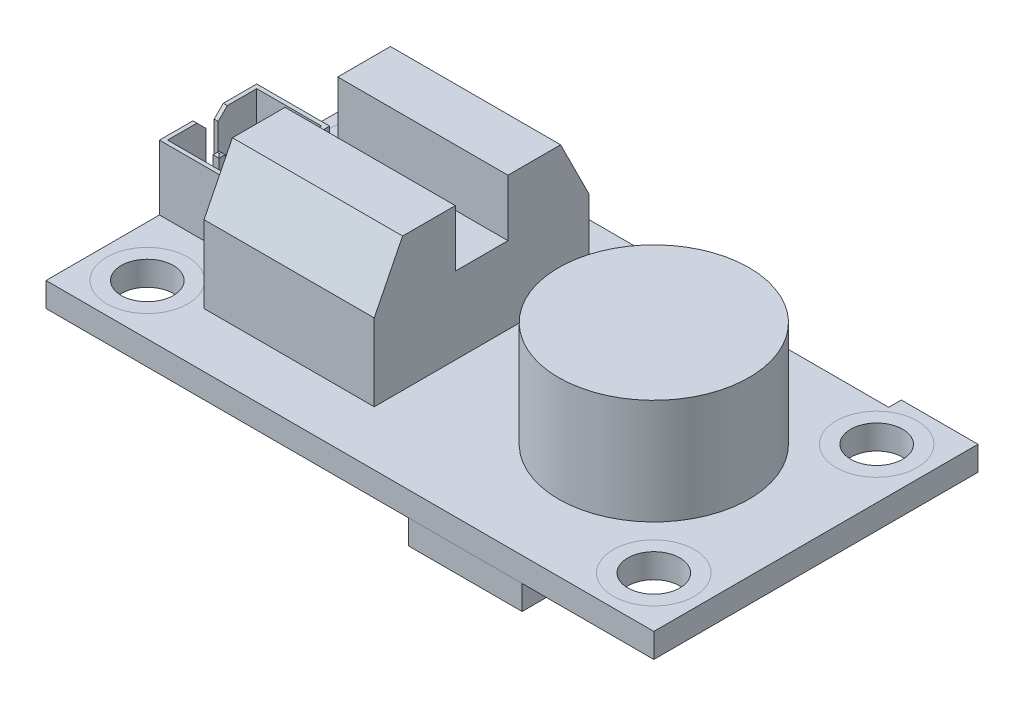
from build123d import *

# Parameters (mm, degrees)
SKETCH1_W               = 38.1
SKETCH1_H               = 20.32
BOSS_EXTRUDE1_DEPTH     = 1.524
F_4_CLEARANCE_HOLE1_D   = 3.2639
SKETCH4_W               = 4.572
SKETCH4_H               = 6.096
BOSS_EXTRUDE2_DEPTH     = 4.064
SKETCH5_R               = 5.969
BOSS_EXTRUDE3_DEPTH     = 6.604
SKETCH6_W               = 10.668
SKETCH6_H               = 13.462
BOSS_EXTRUDE4_DEPTH     = 4.826
BOSS_EXTRUDE5_DEPTH     = 10.668
SKETCH8_W               = 7.874
SKETCH8_H               = 5.588
BOSS_EXTRUDE6_DEPTH     = 3.048
SKETCH9_W               = 7.112
SKETCH9_H               = 5.08
BOSS_EXTRUDE7_DEPTH     = 1.524
SKETCH10_W              = 2.54
SKETCH10_H              = 4.064
BOSS_EXTRUDE8_DEPTH     = 1.016
SKETCH11_W              = 5.08
SKETCH11_H              = 5.08
BOSS_EXTRUDE9_DEPTH     = 1.016
SKETCH12_W              = 4.064
SKETCH12_H              = 2.032
BOSS_EXTRUDE10_DEPTH    = 1.016
SKETCH13_W              = 3.048
SKETCH13_H              = 3.048
BOSS_EXTRUDE11_DEPTH    = 0.508
SKETCH14_W              = 3.048
SKETCH14_H              = 3.556
BOSS_EXTRUDE12_DEPTH    = 1.016
SKETCH15_W              = 2.032
SKETCH15_H              = 4.064
BOSS_EXTRUDE13_DEPTH    = 1.524
SKETCH16_W              = 3.048
SKETCH16_H              = 3.048
BOSS_EXTRUDE14_DEPTH    = 1.016
SKETCH17_R              = 0.508
BOSS_EXTRUDE15_DEPTH    = 1.524
LPATTERN1_COUNT         = 4
LPATTERN1_PITCH         = 2.794
MIRROR1_COPY_1_SKETCH_R = 0.508
MIRROR1_COPY_1_DEPTH    = 1.524
MIRROR1_COPY_2_SKETCH_R = 0.508
MIRROR1_COPY_2_DEPTH    = 1.524
MIRROR1_COPY_3_SKETCH_R = 0.508
MIRROR1_COPY_3_DEPTH    = 1.524
SKETCH22_W              = 13.60805
SKETCH22_H              = 0.79375
CUT_EXTRUDE2_DEPTH      = 1.524
SKETCH24_W              = 4.064
SKETCH24_H              = 5.588
CUT_EXTRUDE3_DEPTH      = 3.556
SKETCH25_W              = 0.381
SKETCH25_H              = 0.381
BOSS_EXTRUDE16_DEPTH    = 3.048
CHAMFER1_SIZE           = 0.127
CUT_EXTRUDE4_DEPTH      = 0.254
CHAMFER2_SIZE           = 1.778
CHAMFER2_SIZE2          = 2.737879906
CHAMFER2_PART_2_SIZE    = 1.778
CHAMFER2_PART_2_SIZE2   = 2.737879906


with BuildPart() as part:
    # Sketch1 → Boss-Extrude1 (new body)
    with BuildSketch(Plane(origin=(0, 0, 0), x_dir=(1, 0, 0), z_dir=(0, 1, 0))):
        Rectangle(SKETCH1_W, SKETCH1_H)
    extrude(amount=BOSS_EXTRUDE1_DEPTH)

    # #4 Clearance Hole1 (through all)
    with Locations(Plane(origin=(0, 1.524, 0), x_dir=(1, 0, 0), z_dir=(0, 1, 0))):
        with Locations((-15.875, 6.985), (15.875, -6.985), (-15.875, -6.985), (15.875, 6.985)):
            Hole(F_4_CLEARANCE_HOLE1_D / 2)

    # Sketch4 → Boss-Extrude2 (add)
    with BuildSketch(Plane(origin=(0, 1.524, 0), x_dir=(1, 0, 0), z_dir=(0, 1, 0))):
        with Locations((-16.764, 0)):
            Rectangle(SKETCH4_W, SKETCH4_H)
    extrude(amount=BOSS_EXTRUDE2_DEPTH)

    # Sketch5 → Boss-Extrude3 (add)
    with BuildSketch(Plane(origin=(0, 1.524, 0), x_dir=(1, 0, 0), z_dir=(0, 1, 0))):
        with Locations((8.89, 0)):
            Circle(SKETCH5_R)
    extrude(amount=BOSS_EXTRUDE3_DEPTH)

    # Sketch6 → Boss-Extrude4 (add)
    with BuildSketch(Plane(origin=(0, 1.524, 0), x_dir=(1, 0, 0), z_dir=(0, 1, 0))):
        with Locations((-7.239, 0)):
            Rectangle(SKETCH6_W, SKETCH6_H)
    extrude(amount=BOSS_EXTRUDE4_DEPTH)

    # Sketch7 → Boss-Extrude5 (add)
    with BuildSketch(Plane.ZY.offset(12.573)):
        Polygon((-6.731, 6.35), (-4.953, 9.906), (-1.651, 9.906), (-1.651, 6.35), align=None)
        Polygon((6.731, 6.35), (4.953, 9.906), (1.651, 9.906), (1.651, 6.35), align=None)
    extrude(amount=-BOSS_EXTRUDE5_DEPTH)

    # Sketch8 → Boss-Extrude6 (add)
    with BuildSketch(Plane.XZ):
        with Locations((7.239, -7.366)):
            Rectangle(SKETCH8_W, SKETCH8_H)
    extrude(amount=BOSS_EXTRUDE6_DEPTH)

    # Sketch9 → Boss-Extrude7 (add)
    with BuildSketch(Plane.XZ):
        with Locations((7.239, 7.62)):
            Rectangle(SKETCH9_W, SKETCH9_H)
    extrude(amount=BOSS_EXTRUDE7_DEPTH)

    # Sketch10 → Boss-Extrude8 (add)
    with BuildSketch(Plane.XZ):
        with Locations((13.589, 0)):
            Rectangle(SKETCH10_W, SKETCH10_H)
    extrude(amount=BOSS_EXTRUDE8_DEPTH)

    # Sketch11 → Boss-Extrude9 (add)
    with BuildSketch(Plane.XZ):
        with Locations((4.191, 0)):
            Rectangle(SKETCH11_W, SKETCH11_H)
    extrude(amount=BOSS_EXTRUDE9_DEPTH)

    # Sketch12 → Boss-Extrude10 (add)
    with BuildSketch(Plane.XZ):
        with Locations((-2.413, 7.112)):
            Rectangle(SKETCH12_W, SKETCH12_H)
    extrude(amount=BOSS_EXTRUDE10_DEPTH)

    # Sketch13 → Boss-Extrude11 (add)
    with BuildSketch(Plane.XZ):
        with Locations((-3.81, -6.096)):
            Rectangle(SKETCH13_W, SKETCH13_H)
    extrude(amount=BOSS_EXTRUDE11_DEPTH)

    # Sketch14 → Boss-Extrude12 (add)
    with BuildSketch(Plane.XZ):
        with Locations((-9.906, -6.35)):
            Rectangle(SKETCH14_W, SKETCH14_H)
    extrude(amount=BOSS_EXTRUDE12_DEPTH)

    # Sketch15 → Boss-Extrude13 (add)
    with BuildSketch(Plane.XZ):
        with Locations((-15.494, 1.27)):
            Rectangle(SKETCH15_W, SKETCH15_H)
    extrude(amount=BOSS_EXTRUDE13_DEPTH)

    # Sketch16 → Boss-Extrude14 (add)
    with BuildSketch(Plane.XZ):
        with Locations((-9.398, 0)):
            Rectangle(SKETCH16_W, SKETCH16_H)
    extrude(amount=BOSS_EXTRUDE14_DEPTH)

    # Sketch17 → Boss-Extrude15 (add)
    with BuildSketch(Plane.XZ):
        with Locations((-11.684, -3.556)):
            Circle(SKETCH17_R)
    boss_extrude15 = extrude(amount=BOSS_EXTRUDE15_DEPTH)

    # LPattern1: Boss-Extrude15 ×4
    with Locations(*[(i * LPATTERN1_PITCH, 0, 0) for i in range(1, LPATTERN1_COUNT)]):
        add(boss_extrude15)

    # Mirror1: Boss-Extrude15 across plane
    add(boss_extrude15.mirror(Plane.XY))

    # Mirror1 copy 1 sketch → Mirror1 copy 1 (add)
    with BuildSketch(Plane(origin=(2.794, 0, 0), x_dir=(1, 0, 0), z_dir=(0, -1, 0))):
        with Locations((-11.684, 3.556)):
            Circle(MIRROR1_COPY_1_SKETCH_R)
    extrude(amount=MIRROR1_COPY_1_DEPTH)

    # Mirror1 copy 2 sketch → Mirror1 copy 2 (add)
    with BuildSketch(Plane(origin=(5.588, 0, 0), x_dir=(1, 0, 0), z_dir=(0, -1, 0))):
        with Locations((-11.684, 3.556)):
            Circle(MIRROR1_COPY_2_SKETCH_R)
    extrude(amount=MIRROR1_COPY_2_DEPTH)

    # Mirror1 copy 3 sketch → Mirror1 copy 3 (add)
    with BuildSketch(Plane(origin=(8.382, 0, 0), x_dir=(1, 0, 0), z_dir=(0, -1, 0))):
        with Locations((-11.684, 3.556)):
            Circle(MIRROR1_COPY_3_SKETCH_R)
    extrude(amount=MIRROR1_COPY_3_DEPTH)

    # Sketch22 → Cut-Extrude2 (cut)
    with BuildSketch(Plane(origin=(0, 1.524, 0), x_dir=(1, 0, 0), z_dir=(0, 1, 0))):
        with Locations((7.439025, 9.763125)):
            Rectangle(SKETCH22_W, SKETCH22_H)
    extrude(amount=-CUT_EXTRUDE2_DEPTH, mode=Mode.SUBTRACT)

    # Sketch24 → Cut-Extrude3 (cut)
    with BuildSketch(Plane(origin=(0, 5.588, 0), x_dir=(1, 0, 0), z_dir=(0, 1, 0))):
        with Locations((-16.764, 0)):
            Rectangle(SKETCH24_W, SKETCH24_H)
    extrude(amount=-CUT_EXTRUDE3_DEPTH, mode=Mode.SUBTRACT)

    # Sketch25 → Boss-Extrude16 (add)
    with BuildSketch(Plane(origin=(0, 2.032, 0), x_dir=(1, 0, 0), z_dir=(0, 1, 0))):
        with Locations((-17.018, 1.3335)):
            Rectangle(SKETCH25_W, SKETCH25_H)
        with Locations((-17.018, -1.3335)):
            Rectangle(SKETCH25_W, SKETCH25_H)
    extrude(amount=BOSS_EXTRUDE16_DEPTH)

    # Chamfer1
    chamfer1_edges = [part.edges().sort_by_distance(p)[0] for p in [
        (-17.018, 5.08, -1.524),
        (-17.2085, 5.08, -1.3335),
        (-17.018, 5.08, -1.143),
        (-16.8275, 5.08, -1.3335),
        (-17.018, 5.08, 1.143),
        (-17.2085, 5.08, 1.3335),
        (-17.018, 5.08, 1.524),
        (-16.8275, 5.08, 1.3335),
    ]]
    chamfer(chamfer1_edges, length=CHAMFER1_SIZE)

    # Sketch26 → Cut-Extrude4 (cut)
    with BuildSketch(Plane.ZY.offset(19.05)):
        Polygon((-0.9525, 5.588), (-0.381, 5.0165), (-0.381, 2.286), (0.381, 2.286), (0.381, 5.0165), (0.9525, 5.588), align=None)
    extrude(amount=-CUT_EXTRUDE4_DEPTH, mode=Mode.SUBTRACT)

    # Chamfer2
    chamfer2_edges = [part.edges().sort_by_distance(p)[0] for p in [
        (3.302, -3.048, -7.366),
    ]]
    chamfer2_side = [part.faces().sort_by_distance(p)[0] for p in [
        (3.302, -1.524, -7.366),
    ]]
    chamfer(chamfer2_edges, length=CHAMFER2_SIZE, length2=CHAMFER2_SIZE2, reference=chamfer2_side[0])

    # Chamfer2 part 2
    chamfer2_part_2_edges = [part.edges().sort_by_distance(p)[0] for p in [
        (11.176, -3.048, -7.366),
    ]]
    chamfer2_part_2_side = [part.faces().sort_by_distance(p)[0] for p in [
        (11.176, -1.524, -7.366),
    ]]
    chamfer(chamfer2_part_2_edges, length=CHAMFER2_PART_2_SIZE, length2=CHAMFER2_PART_2_SIZE2, reference=chamfer2_part_2_side[0])


solid = part.part
